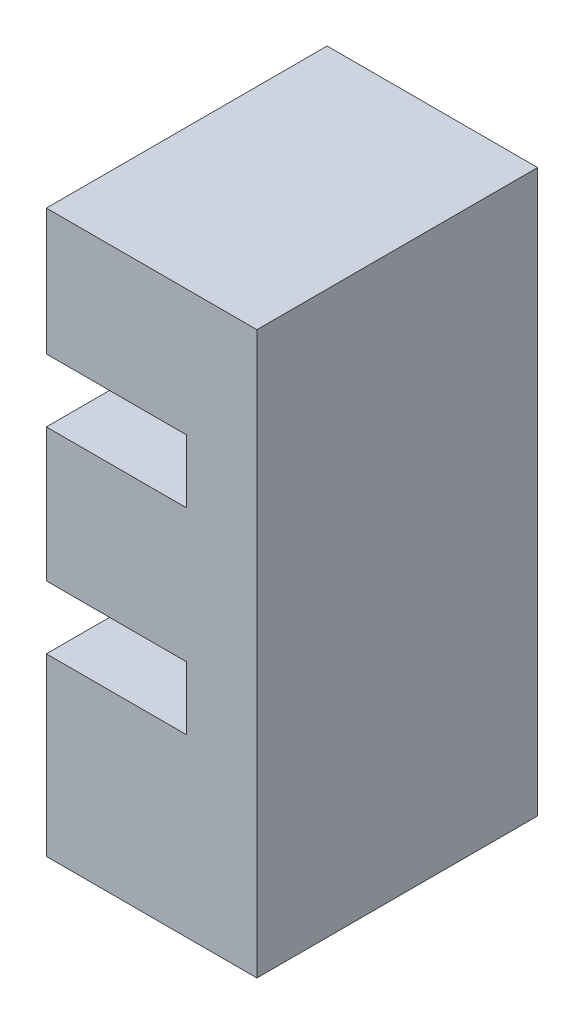
from build123d import *

# Parameters (mm, degrees)
BOSS_EXTRUDE3_DEPTH = 5.08


with BuildPart() as part:
    # Sketch1 → Boss-Extrude3 (new body)
    with BuildSketch(Plane.XY):
        Polygon((-1.905, 1.143), (-1.905, -1.27), (0.635, -1.27), (0.635, -2.413), (-1.905, -2.413), (-1.905, -5.588), (1.905, -5.588), (1.905, 4.572), (-1.905, 4.572), (-1.905, 2.286), (0.635, 2.286), (0.635, 1.143), align=None)
    extrude(amount=BOSS_EXTRUDE3_DEPTH)


solid = part.part
